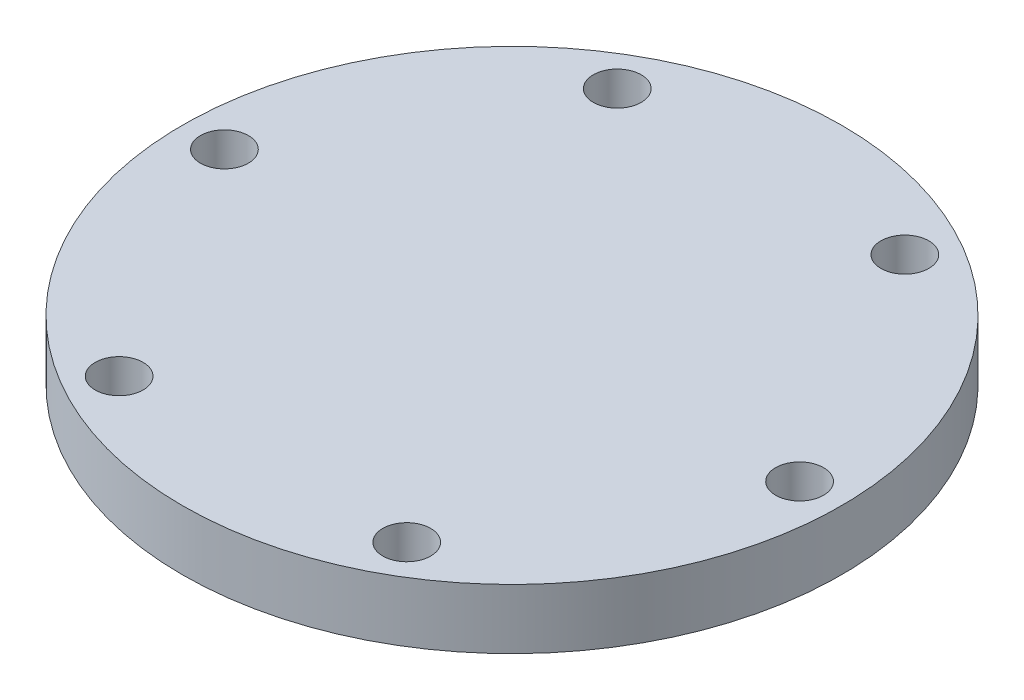
from build123d import *

# Parameters (mm, degrees)
SKETCH_1_R      = 27.5
SKETCH_1_R_2    = 2
EXTRUDE_1_DEPTH = 5


with BuildPart() as part:
    # Эскиз1 → Бобышка-Вытянуть1 (new body)
    with BuildSketch(Plane(origin=(0, 0, 0), x_dir=(1, 0, 0), z_dir=(0, 1, 0))):
        Circle(SKETCH_1_R)
        with Locations((-23.99817593, 0)):
            Circle(SKETCH_1_R_2, mode=Mode.SUBTRACT)
        with Locations((-11.999087965, 20.78303)):
            Circle(SKETCH_1_R_2, mode=Mode.SUBTRACT)
        with Locations((11.999087965, 20.78303)):
            Circle(SKETCH_1_R_2, mode=Mode.SUBTRACT)
        with Locations((23.99817593, 0)):
            Circle(SKETCH_1_R_2, mode=Mode.SUBTRACT)
        with Locations((11.999087965, -20.78303)):
            Circle(SKETCH_1_R_2, mode=Mode.SUBTRACT)
        with Locations((-11.999087965, -20.78303)):
            Circle(SKETCH_1_R_2, mode=Mode.SUBTRACT)
    extrude(amount=EXTRUDE_1_DEPTH)


solid = part.part
